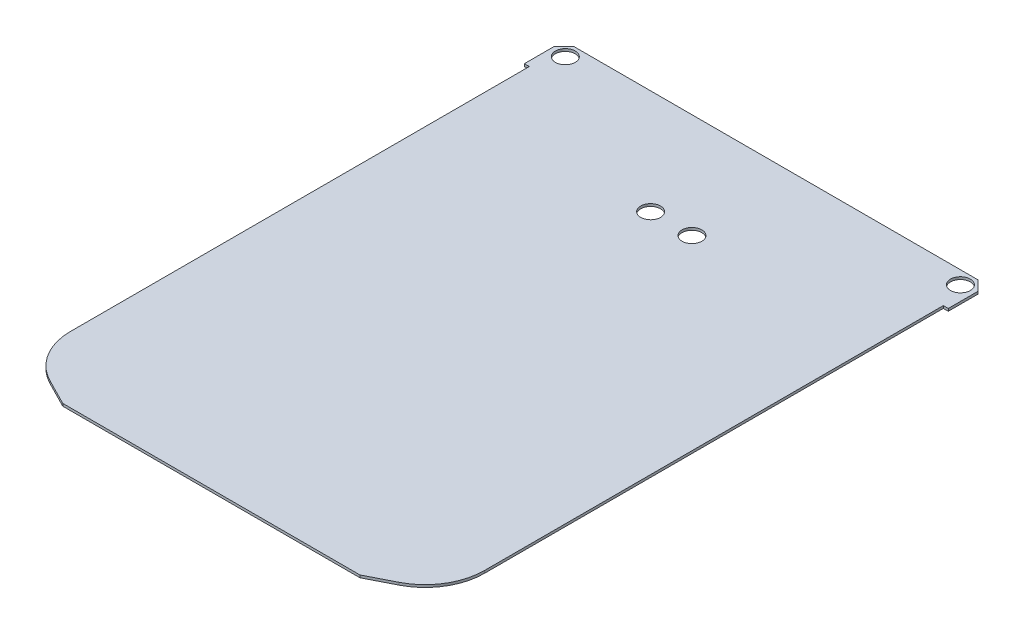
from build123d import *

# Parameters (mm, degrees)
SKETCH1_R           = 1
BOSS_EXTRUDE1_DEPTH = 0.25
SKETCH2_R           = 1
CUT_EXTRUDE1_DEPTH  = 4.5
FILLET1_R           = 6


with BuildPart() as part:
    # Sketch1 → Boss-Extrude1 (new body)
    with BuildSketch(Plane(origin=(0, 0, 0), x_dir=(1, 0, 0), z_dir=(0, 1, 0))):
        Polygon((-21.4, 26.5), (-20.9, 26.5), (-20.9, -23.5), (-15, -26.5), (15, -26.5), (20.9, -23.5), (20.9, 26.5), (21.4, 26.5), (21.4, 29.5), (20.4, 30.5), (-20.4, 30.5), (-21.4, 29.5), align=None)
        with Locations((-19.944365081, 29.181392426)):
            Circle(SKETCH1_R, mode=Mode.SUBTRACT)
        with Locations((19.944365081, 29.181392426)):
            Circle(SKETCH1_R, mode=Mode.SUBTRACT)
    extrude(amount=BOSS_EXTRUDE1_DEPTH)

    # Sketch2 → Cut-Extrude1 (cut)
    with BuildSketch(Plane(origin=(0, 0.25, 0), x_dir=(1, 0, 0), z_dir=(0, 1, 0))):
        with Locations((-2.084530189, 19.934465076)):
            Circle(SKETCH2_R)
        with Locations((2.084530189, 19.934465076)):
            Circle(SKETCH2_R)
    extrude(amount=-CUT_EXTRUDE1_DEPTH, mode=Mode.SUBTRACT)

    # Fillet1
    fillet1_edges = [part.edges().sort_by_distance(p)[0] for p in [
        (20.9, 0.125, 23.5),
        (-20.9, 0.125, 23.5),
    ]]
    fillet(fillet1_edges, radius=FILLET1_R)


solid = part.part
